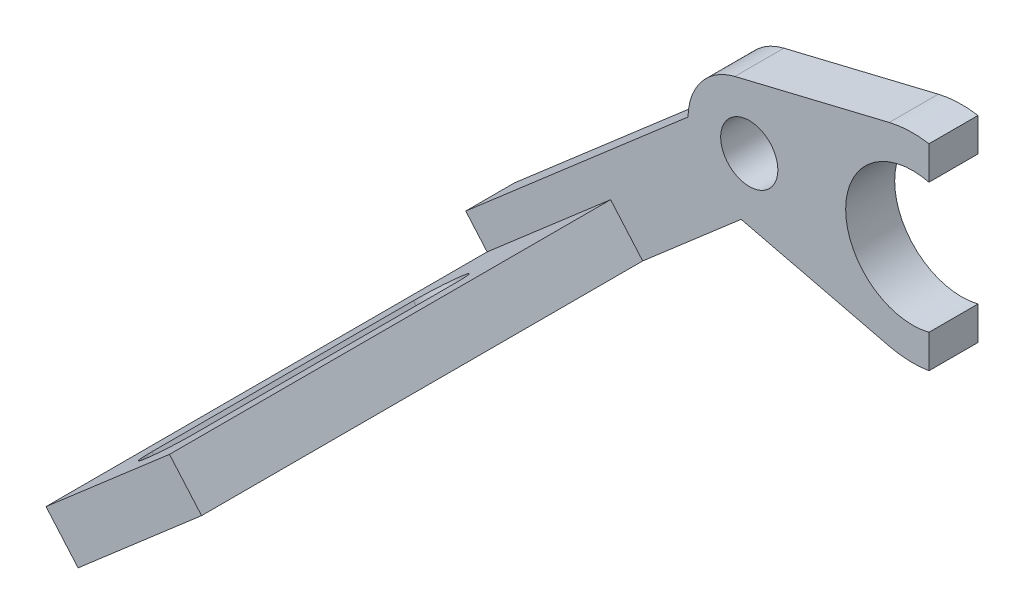
from build123d import *

# Parameters (mm, degrees)
ESBO_O1_R                = 1.75
RESSALTO_EXTRUS_O1_DEPTH = 3
ESBO_O2_W                = 10
ESBO_O2_H                = 30
RESSALTO_EXTRUS_O2_DEPTH = 3


with BuildPart() as part:
    # Esboço1 → Ressalto-extrusão1 (new body)
    with BuildSketch(Plane.XY):
        with BuildLine():
            ThreePointArc((-0.475822638, -3.719689882), (3.744330631, 0.206126489), (-0.88125, 3.644982639))
            ThreePointArc((-0.88125, 3.644982639), (-2.928276933, 2.342582807), (-3.749526707, 0.059577464))
            ThreePointArc((-3.749526707, 0.059577464), (-2.965124722, -2.295764662), (-0.88125, -3.644982639))
            Line((-0.88125, -3.644982639), (-0.496863485, -3.737916035))
            Line((-0.496863485, -3.737916035), (-0.475822638, -3.719689882))
        make_face()
        Circle(ESBO_O1_R, mode=Mode.SUBTRACT)
        with BuildLine():
            Line((8.5665, 5.929171759), (-0.88125, 3.644982639))
            ThreePointArc((-0.88125, 3.644982639), (3.744330631, 0.206126489), (-0.475822638, -3.719689882))
            Line((-0.475822638, -3.719689882), (-0.496863485, -3.737916035))
            Line((-0.496863485, -3.737916035), (8.5665, -5.929171759))
            ThreePointArc((8.5665, -5.929171759), (9.778798941, -6.095988032), (11, -6.017474553))
            Line((11, -6.017474553), (11, -3.97617907))
            ThreePointArc((11, -3.97617907), (5.9, 0), (11, 3.97617907))
            Line((11, 3.97617907), (11, 6.017474553))
            ThreePointArc((11, 6.017474553), (9.778798941, 6.095988032), (8.5665, 5.929171759))
        make_face()
        with BuildLine():
            ThreePointArc((-0.88125, -3.644982639), (-2.965124722, -2.295764662), (-3.749526707, 0.059577464))
            Line((-3.749526707, 0.059577464), (-17.354889152, -11.725757183))
            Line((-17.354889152, -11.725757183), (-14.081185083, -15.505024529))
            Line((-14.081185083, -15.505024529), (-0.496863485, -3.737916035))
            Line((-0.496863485, -3.737916035), (-0.88125, -3.644982639))
        make_face()
    extrude(amount=RESSALTO_EXTRUS_O1_DEPTH)

    # Esboço2 → Ressalto-extrusão2 (add)
    with BuildSketch(Plane(origin=(1.636852034, -1.889633673, 0), x_dir=(0.755853469, 0.654740814, 0), z_dir=(0.654740814, -0.755853469, 0))):
        with Locations((-15.795084972, 15)):
            Rectangle(ESBO_O2_W, ESBO_O2_H)
        with BuildLine():
            Line((-14.095084972, 26), (-14.095084972, 10))
            ThreePointArc((-14.095084972, 10), (-15.795084972, 8.3), (-17.495084972, 10))
            Line((-17.495084972, 10), (-17.495084972, 26))
            ThreePointArc((-17.495084972, 26), (-15.795084972, 27.7), (-14.095084972, 26))
        make_face(mode=Mode.SUBTRACT)
    extrude(amount=-RESSALTO_EXTRUS_O2_DEPTH)


solid = part.part
